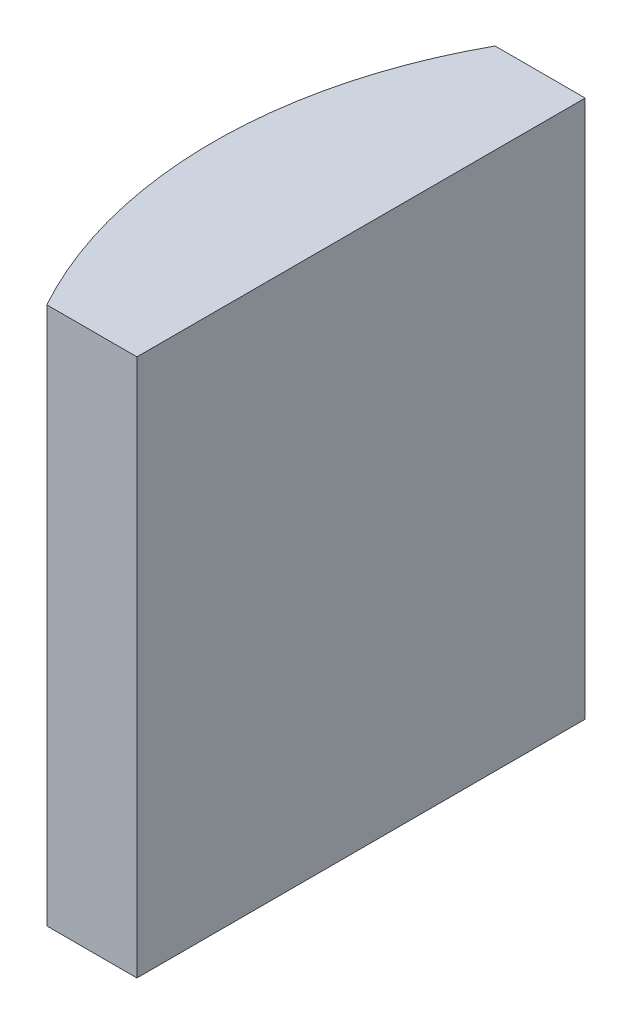
from build123d import *

# Parameters (mm, degrees)
EXTRUDE_1_DEPTH = 12


with BuildPart() as part:
    # 草图1 → 凸台-拉伸1 (new body)
    with BuildSketch(Plane(origin=(0, 0, 0), x_dir=(1, 0, 0), z_dir=(0, 1, 0))):
        with BuildLine():
            Line((-4.695519393, 5), (-2.684795665, 5))
            Line((-2.684795665, 5), (-2.684795665, -5))
            Line((-2.684795665, -5), (-4.695519393, -5))
            ThreePointArc((-4.695519393, -5), (-5.984795665, 0), (-4.695519393, 5))
        make_face()
    extrude(amount=EXTRUDE_1_DEPTH)


solid = part.part
